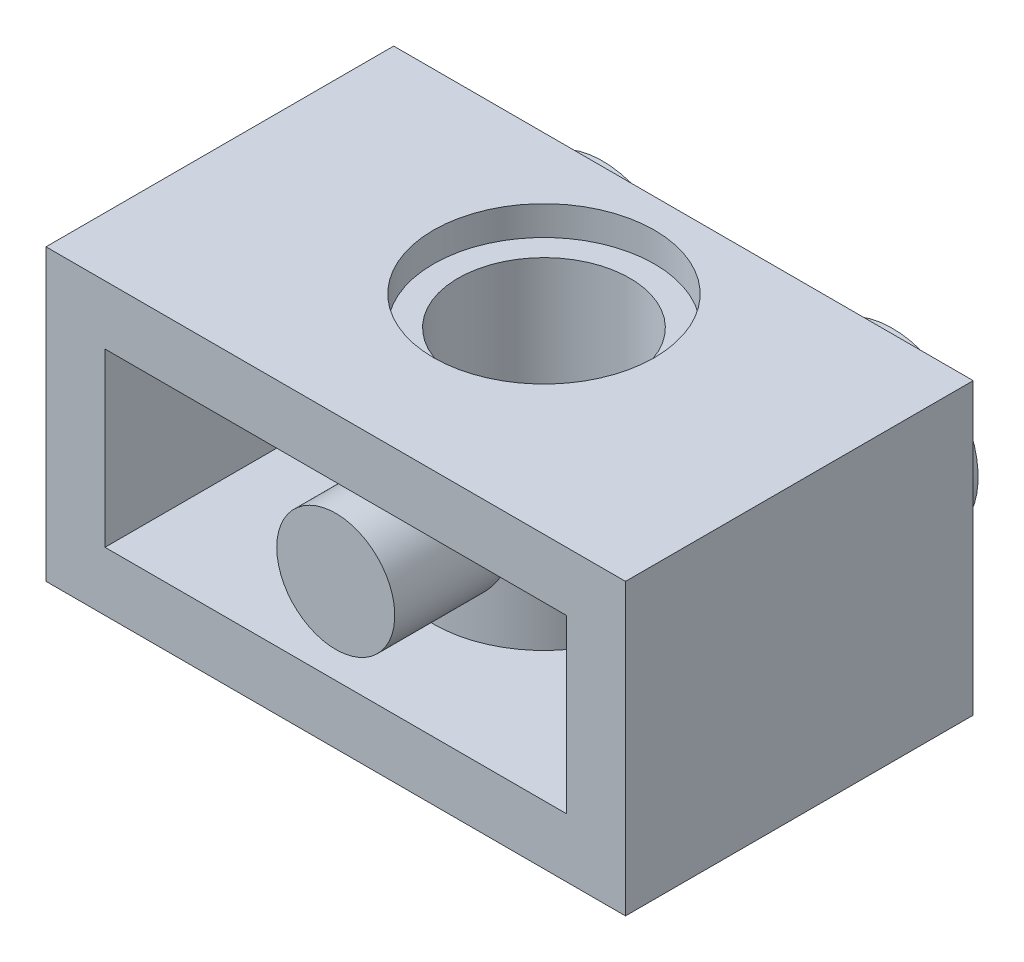
from build123d import *

# Parameters (mm, degrees)
SKETCH1_W                = 16.13
SKETCH1_H                = 9.678
BOSS_EXTRUDE1_DEPTH      = 8.065
SKETCH2_W                = 12.845
SKETCH2_H                = 4.78
CUT_EXTRUDE1_DEPTH       = 8.0355
BOSS_EXTRUDE2_DEPTH      = 4.78
SKETCH4_W                = 2.39
SKETCH4_H                = 1.78
SKETCH5_W                = 2.39
SKETCH5_H                = 1.78
SKETCH7_W                = 1.6425
SKETCH7_H                = 3.195419505
M3_CLEARANCE_HOLE1_D     = 3.285
M3_CLEARANCE_HOLE1_DEPTH = 1.78


with BuildPart() as part:
    # Sketch1 → Boss-Extrude1 (new body)
    with BuildSketch(Plane(origin=(0, 4.0325, 0), x_dir=(-1, 0, 0), z_dir=(0, 1, 0))):
        Rectangle(SKETCH1_W, SKETCH1_H)
    extrude(amount=-BOSS_EXTRUDE1_DEPTH)

    # Sketch2 → Cut-Extrude1 (cut)
    with BuildSketch(Plane.XY.offset(4.839)):
        Rectangle(SKETCH2_W, SKETCH2_H)
    extrude(amount=-CUT_EXTRUDE1_DEPTH, mode=Mode.SUBTRACT)

    # Sketch3 → Boss-Extrude2 (add)
    with BuildSketch(Plane.XZ.offset(-2.39)):
        with BuildLine():
            Line((2.106130278, -3.1965), (-2.106130278, -3.1965))
            ThreePointArc((-2.106130278, -3.1965), (0, 2.119), (2.106130278, -3.1965))
        make_face()
    extrude(amount=BOSS_EXTRUDE2_DEPTH)

    # Sketch4 → Revolve1 (revolve)
    with BuildSketch(Plane.XZ):
        with Locations((5.2275, -5.729)):
            Rectangle(SKETCH4_W, SKETCH4_H)
    revolve(axis=Axis((4.0325, 0, -4.839), (0, 0, -1)))

    # Sketch5 → Revolve2 (revolve)
    with BuildSketch(Plane.XZ):
        with Locations((-2.8375, -5.729)):
            Rectangle(SKETCH5_W, SKETCH5_H)
    revolve(axis=Axis((-4.0325, 0, -4.839), (0, 0, -1)))

    # Sketch6 → Cut-Revolve1 (revolve, cut)
    with BuildSketch(Plane(origin=(0, 0, -0.956), x_dir=(-1, 0, 0), z_dir=(0, 0, -1))):
        Polygon((-3.075, -4.0325), (0, -4.0325), (0, 4.0325), (-3.075, 4.0325), (-3.075, 3.2175), (-2.39, 3.2175), (-2.39, -3.2175), (-3.075, -3.2175), align=None)
    revolve(axis=Axis((0, -4.0325, -0.956), (0, 1, 0)), mode=Mode.SUBTRACT)

    # Sketch7 → Revolve3 (revolve)
    with BuildSketch(Plane(origin=(0, 0, 0), x_dir=(1, 0, 0), z_dir=(0, 1, 0))):
        with Locations((-0.82125, -3.241290248)):
            Rectangle(SKETCH7_W, SKETCH7_H)
    revolve(axis=Axis((0, 0, 4.839), (0, 0, -1)))

    # M3 Clearance Hole1
    with Locations(Plane(origin=(0, 0, -6.619), x_dir=(-1, 0, 0), z_dir=(0, 0, -1))):
        with Locations((4.0325, 0), (-4.0325, 0)):
            Hole(M3_CLEARANCE_HOLE1_D / 2, depth=M3_CLEARANCE_HOLE1_DEPTH)


solid = part.part
